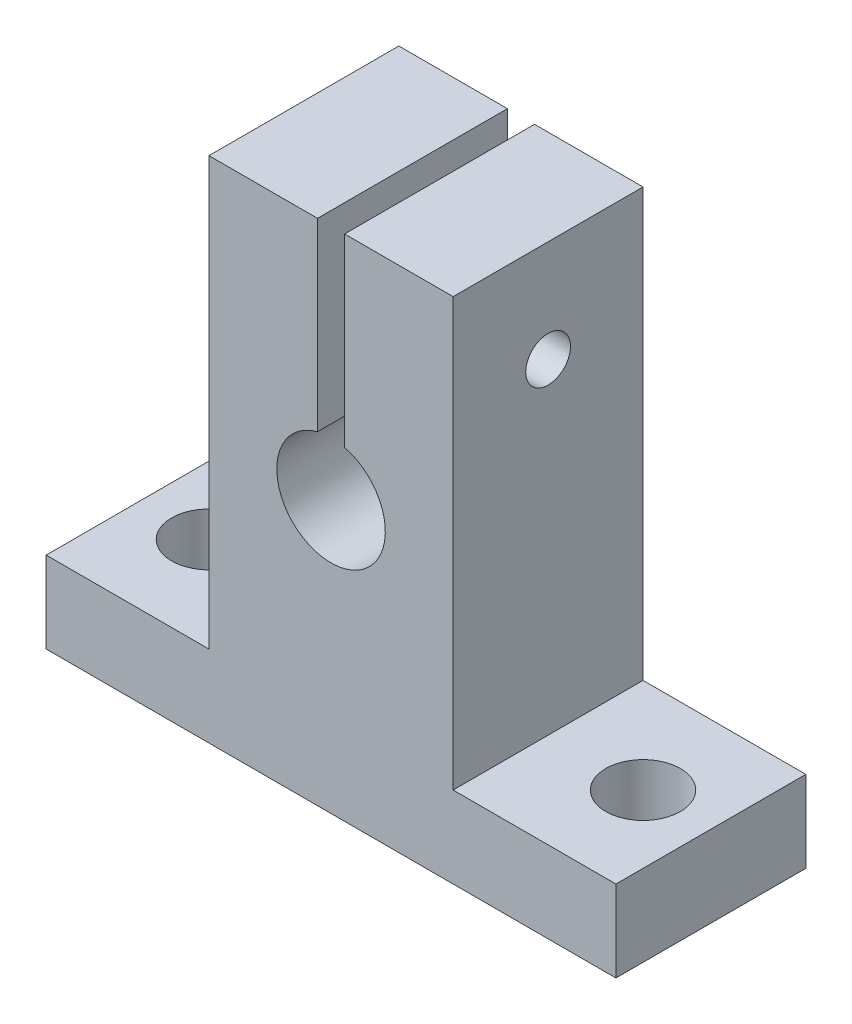
from build123d import *

# Parameters (mm, degrees)
BOSS_EXTRUDE1_DEPTH         = 14
TAP_DRILL_FOR_M4X0_7_TAP2_D = 3.3
F_12_0_12_DIAMETER_HOLE1_D  = 8
TAP_DRILL_FOR_M5X0_8_TAP1_D = 5.5


with BuildPart() as part:
    # Sketch2 → Boss-Extrude1 (new body)
    with BuildSketch(Plane.XY):
        Polygon((-1, 0), (-1, 17.5), (-9, 17.5), (-9, -14), (-21, -14), (-21, -20), (0, -20), (0, 0), align=None)
    boss_extrude1 = extrude(amount=BOSS_EXTRUDE1_DEPTH)

    # Mirror1: Boss-Extrude1 across plane
    add(boss_extrude1.mirror(Plane(origin=(0, -20, 14), x_dir=(0, 0, 1), z_dir=(-1, 0, 0))))

    # Tap Drill for M4x0.7 Tap2 (through all)
    with Locations(Plane.ZY.offset(9)):
        with Locations((7, 10)):
            Hole(TAP_DRILL_FOR_M4X0_7_TAP2_D / 2)

    # Ø12.0 (12) Diameter Hole1 (through all)
    with Locations(Plane(origin=(0, 0, 0), x_dir=(1, 0, 0), z_dir=(0, 0, -1))):
        with Locations((0, 0)):
            Hole(F_12_0_12_DIAMETER_HOLE1_D / 2)

    # Tap Drill for M5x0.8 Tap1 (through all)
    with Locations(Plane(origin=(0, -20, 0), x_dir=(-1, 0, 0), z_dir=(0, -1, 0))):
        with Locations((-16, -7), (16, -7)):
            Hole(TAP_DRILL_FOR_M5X0_8_TAP1_D / 2)


solid = part.part
